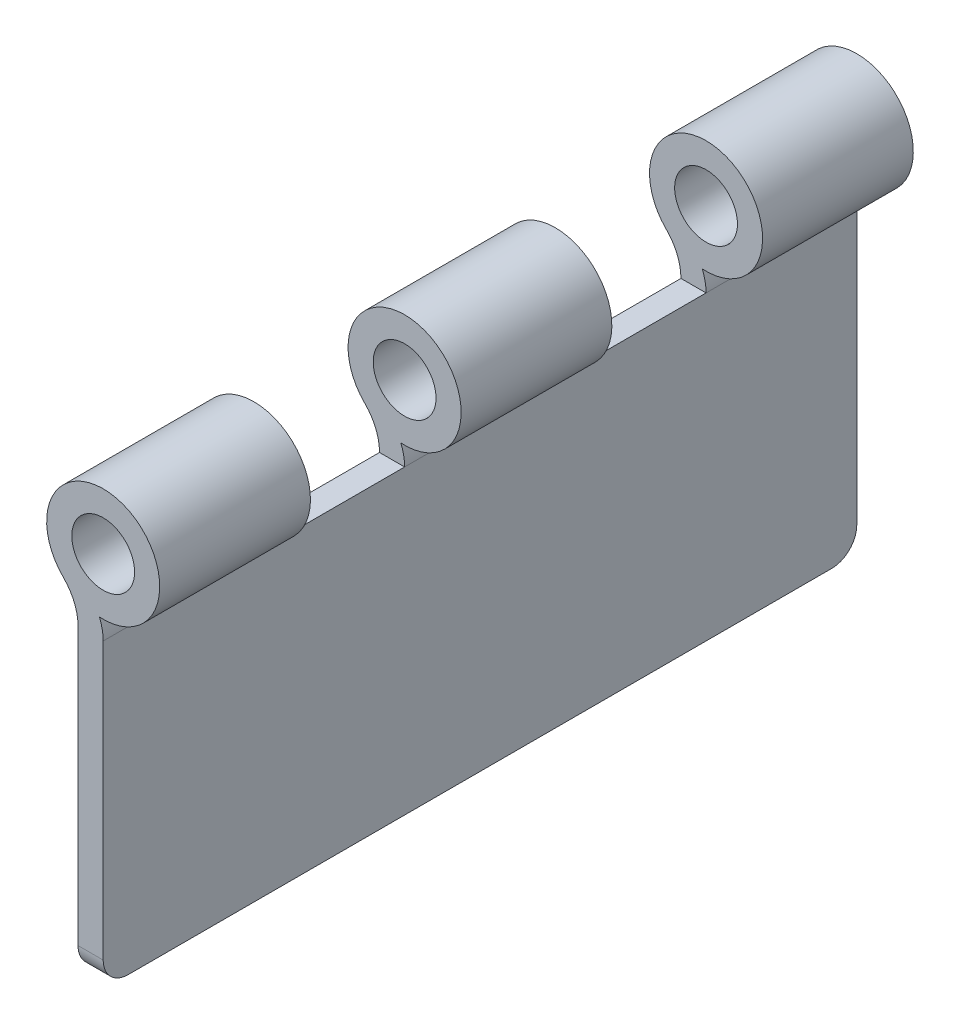
from build123d import *

# Parameters (mm, degrees)
SKETCH1_R           = 5.715
SKETCH1_R_2         = 3.175
BOSS_EXTRUDE1_DEPTH = 38.1
SKETCH2_R           = 3.175
CUT_EXTRUDE1_DEPTH  = 7.62
FILLET1_R           = 2.54


with BuildPart() as part:
    # Sketch1 → Boss-Extrude1 (new body, symmetric)
    with BuildSketch(Plane.XY):
        with BuildLine():
            Line((-2.54, 0), (0, 0))
            Line((0, 0), (0, 30.48))
            ThreePointArc((0, 30.48), (-0.096177955, 31.457600747), (-0.381023909, 32.39771574))
            ThreePointArc((-0.381023909, 32.39771574), (-2.351034724, 32.890982749), (-4.024171598, 34.042011834))
            ThreePointArc((-4.024171598, 34.042011834), (-2.925884615, 32.409423077), (-2.54, 30.48))
            Line((-2.54, 30.48), (-2.54, 0))
        make_face()
        with Locations((0, 38.1)):
            Circle(SKETCH1_R)
        with Locations((0, 38.1)):
            Circle(SKETCH1_R_2, mode=Mode.SUBTRACT)
    extrude(amount=BOSS_EXTRUDE1_DEPTH, both=True)

    # Sketch2 → Cut-Extrude1 (cut, symmetric)
    with BuildSketch(Plane.XY.offset(15.24)):
        with BuildLine():
            ThreePointArc((0, 30.48), (-0.096177955, 31.457600747), (-0.381023909, 32.39771574))
            ThreePointArc((-0.381023909, 32.39771574), (2.351034724, 43.309017251), (-4.024171598, 34.042011834))
            ThreePointArc((-4.024171598, 34.042011834), (-2.925884615, 32.409423077), (-2.54, 30.48))
            Line((-2.54, 30.48), (0, 30.48))
        make_face()
        with Locations((0, 38.1)):
            Circle(SKETCH2_R, mode=Mode.SUBTRACT)
    cut_extrude1 = extrude(amount=CUT_EXTRUDE1_DEPTH, both=True, mode=Mode.SUBTRACT)

    # Mirror1: Cut-Extrude1 across plane
    add(cut_extrude1.mirror(Plane.XY), mode=Mode.SUBTRACT)

    # Fillet1
    fillet1_edges = [part.edges().sort_by_distance(p)[0] for p in [
        (-1.27, 0, 38.1),
        (-1.27, 0, -38.1),
    ]]
    fillet(fillet1_edges, radius=FILLET1_R)


solid = part.part
